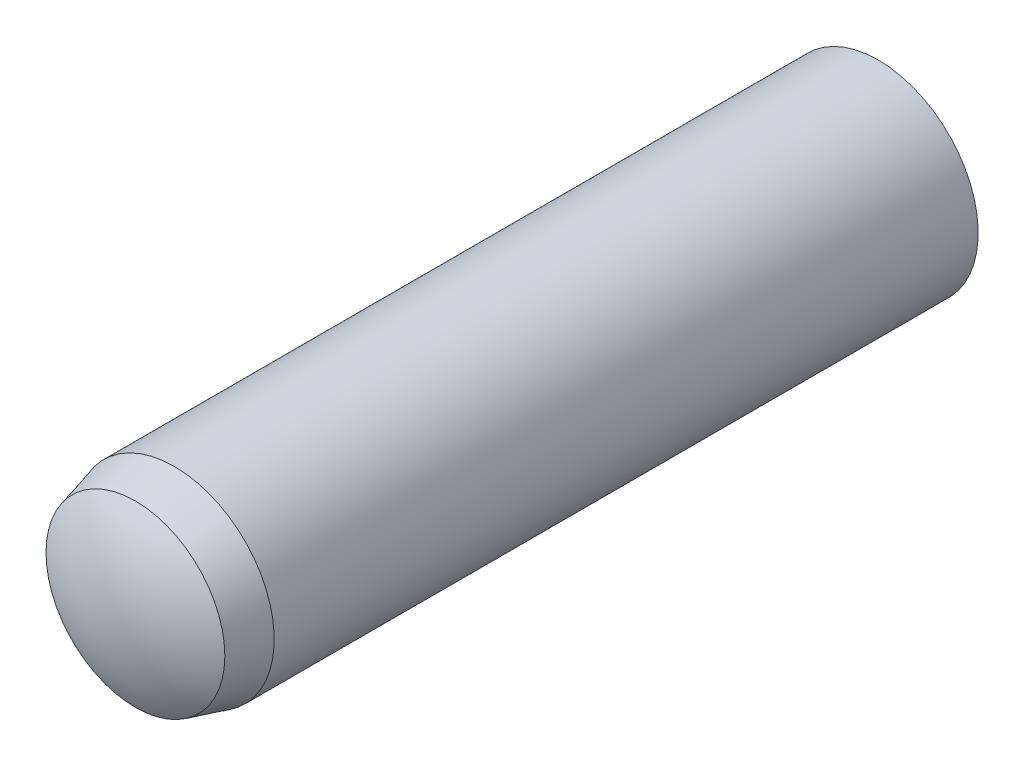
from build123d import *


with BuildPart() as part:
    # Sketch3 → Revolve1 (revolve)
    with BuildSketch(Plane(origin=(0, 0, 0), x_dir=(0, 0, -1), z_dir=(1, 0, 0))):
        with BuildLine():
            Line((-6, 0), (6, 0))
            ThreePointArc((6, 0), (5.885076627, 0.783022988), (5.55, 1.5))
            Line((5.55, 1.5), (-5.025, 1.5))
            Line((-5.025, 1.5), (-5.61, 1.343249722))
            ThreePointArc((-5.61, 1.343249722), (-5.90052754, 0.699360389), (-6, 0))
        make_face()
    revolve(axis=Axis((0, 0, 6), (0, 0, -1)))


solid = part.part
